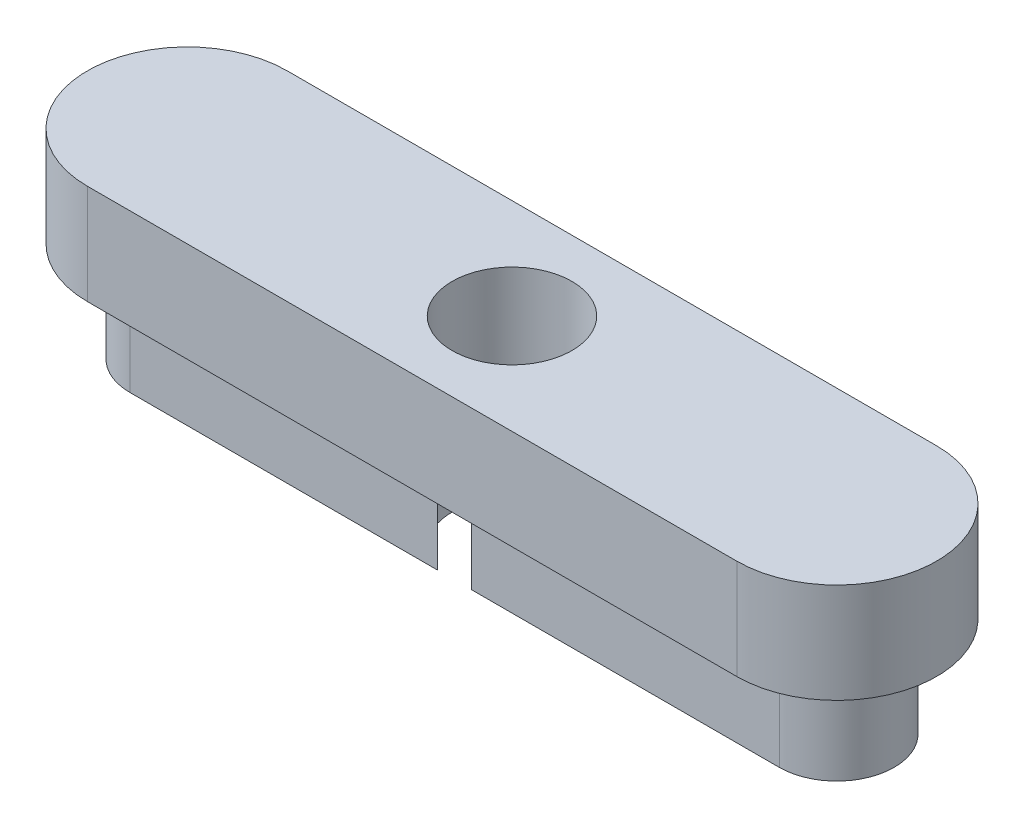
from build123d import *

# Parameters (mm, degrees)
BOSS_EXTRUDE1_DEPTH = 2
BOSS_EXTRUDE2_DEPTH = 2
SKETCH3_R           = 1.2
CUT_EXTRUDE1_DEPTH  = 5


with BuildPart() as part:
    # Sketch1 → Boss-Extrude1 (new body)
    with BuildSketch(Plane(origin=(0, 0, 0), x_dir=(1, 0, 0), z_dir=(0, 1, 0))):
        with BuildLine():
            Line((-6.5, 2), (6.5, 2))
            ThreePointArc((6.5, 2), (8.5, 0), (6.5, -2))
            Line((6.5, -2), (-6.5, -2))
            ThreePointArc((-6.5, -2), (-8.5, 0), (-6.5, 2))
        make_face()
    extrude(amount=BOSS_EXTRUDE1_DEPTH)

    # Sketch2 → Boss-Extrude2 (add)
    with BuildSketch(Plane.XZ):
        with BuildLine():
            Line((-6.5, 1.15), (6.5, 1.15))
            ThreePointArc((6.5, 1.15), (7.65, 0), (6.5, -1.15))
            Line((6.5, -1.15), (-6.5, -1.15))
            ThreePointArc((-6.5, -1.15), (-7.65, 0), (-6.5, 1.15))
        make_face()
    extrude(amount=BOSS_EXTRUDE2_DEPTH)

    # Sketch3 → Cut-Extrude1 (cut, through all)
    with BuildSketch(Plane.XZ.offset(2)):
        Circle(SKETCH3_R)
    extrude(amount=-CUT_EXTRUDE1_DEPTH, mode=Mode.SUBTRACT)


solid = part.part
